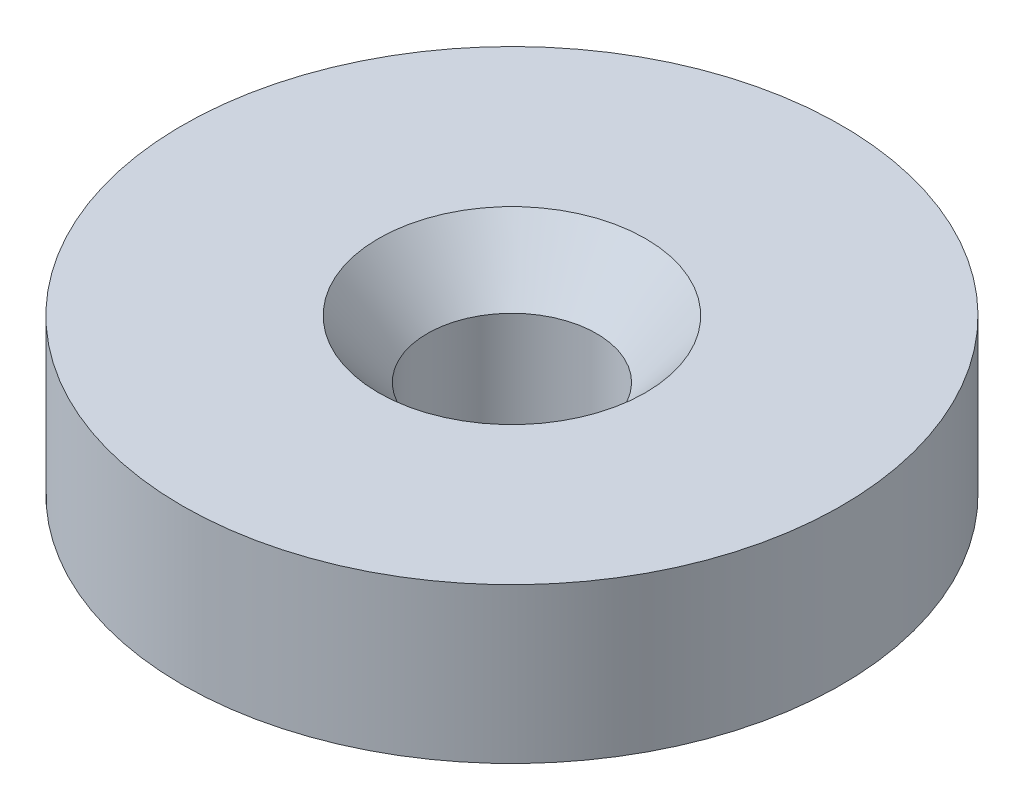
from build123d import *


with BuildPart() as part:
    # Эскиз1 → Повернуть1 (revolve)
    with BuildSketch(Plane(origin=(0, 0, 0), x_dir=(0, 0, -1), z_dir=(1, 0, 0))):
        Polygon((2.567742884, 0), (10, 0), (10, 4.7), (4.05143488, 4.7), (2.567742884, 2.946545823), align=None)
    revolve(axis=Axis((0, 28.90728443, 0), (0, -1, 0)))


solid = part.part
